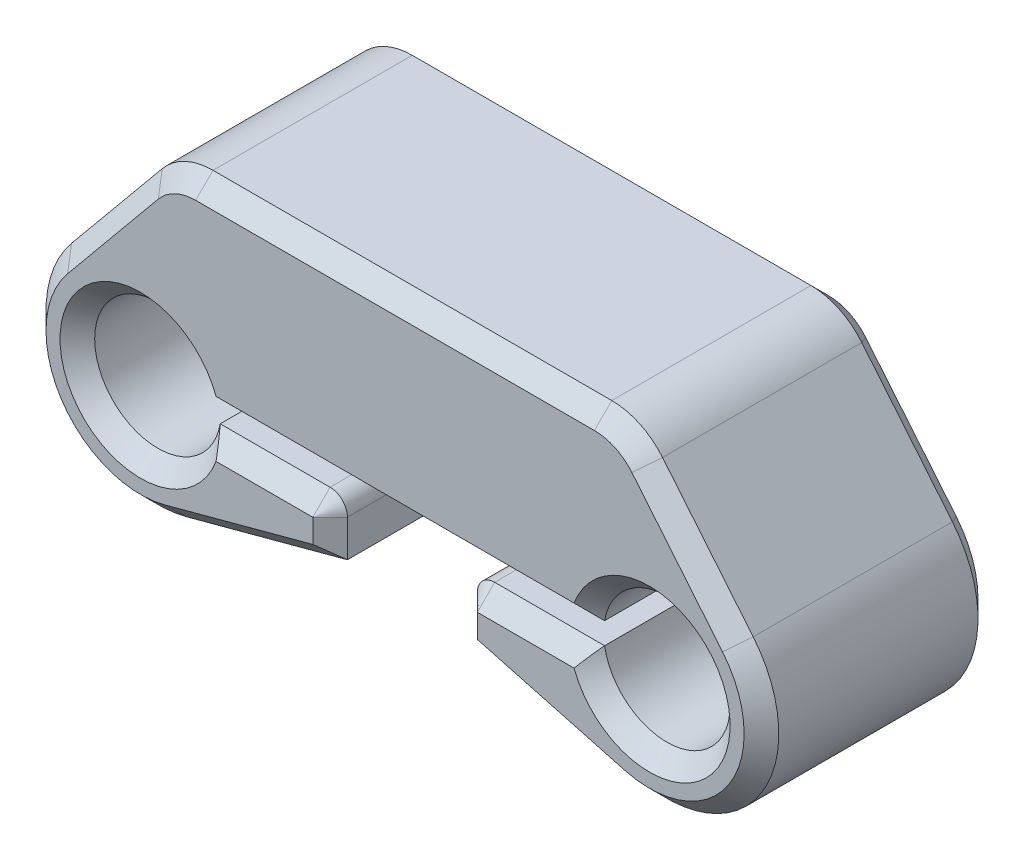
from build123d import *

# Parameters (mm, degrees)
BOSS_EXTRUDE2_DEPTH = 34.29
CHAMFER1_SIZE       = 2.54
CHAMFER2_SIZE       = 2.54


with BuildPart() as part:
    # Sketch2 → Boss-Extrude2 (new body)
    with BuildSketch(Plane.XY):
        with BuildLine():
            Line((-29.230640855, 30.0736), (29.230640855, 30.0736))
            ThreePointArc((29.230640855, 30.0736), (33.347275907, 29.151687047), (36.677508311, 26.562061635))
            Line((36.677508311, 26.562061635), (49.972274675, 10.43878478))
            ThreePointArc((49.972274675, 10.43878478), (51.110407437, -8.880095747), (33.055391111, -15.846506335))
            Line((33.055391111, -15.846506335), (9.525, -9.525))
            Line((9.525, -9.525), (9.525, -4.1275))
            ThreePointArc((9.525, -4.1275), (10.268948776, -2.331448776), (12.065, -1.5875))
            Line((12.065, -1.5875), (28.178527264, -1.5875))
            ThreePointArc((28.178527264, -1.5875), (46.5836, 0), (28.178527264, 1.5875))
            Line((28.178527264, 1.5875), (-28.178527264, 1.5875))
            ThreePointArc((-28.178527264, 1.5875), (-46.5836, 0), (-28.178527264, -1.5875))
            Line((-28.178527264, -1.5875), (-12.065, -1.5875))
            ThreePointArc((-12.065, -1.5875), (-10.268948776, -2.331448776), (-9.525, -4.1275))
            Line((-9.525, -4.1275), (-9.525, -9.525))
            Line((-9.525, -9.525), (-33.055391111, -15.846506335))
            ThreePointArc((-33.055391111, -15.846506335), (-51.110407437, -8.880095747), (-49.972274675, 10.43878478))
            Line((-49.972274675, 10.43878478), (-36.677508311, 26.562061635))
            ThreePointArc((-36.677508311, 26.562061635), (-33.347275907, 29.151687047), (-29.230640855, 30.0736))
        make_face()
    extrude(amount=BOSS_EXTRUDE2_DEPTH)

    # Chamfer1
    chamfer1_edges = [part.edges().sort_by_distance(p)[0] for p in [
        (33.347275907, 29.151687047, 34.29),
        (0, 30.0736, 34.29),
        (-33.347275907, 29.151687047, 34.29),
        (-43.324891493, 18.500423208, 34.29),
        (-51.110407437, -8.880095747, 34.29),
        (-21.290195556, -12.685753168, 34.29),
        (-9.525, -6.82625, 34.29),
        (-10.268948776, -2.331448776, 34.29),
        (-20.121763632, -1.5875, 34.29),
        (-46.5836, 0, 34.29),
        (51.110407437, -8.880095747, 34.29),
        (0, 1.5875, 34.29),
        (46.5836, 0, 34.29),
        (20.121763632, -1.5875, 34.29),
        (10.268948776, -2.331448776, 34.29),
        (9.525, -6.82625, 34.29),
        (21.290195556, -12.685753168, 34.29),
        (43.324891493, 18.500423208, 34.29),
    ]]
    chamfer(chamfer1_edges, length=CHAMFER1_SIZE)

    # Chamfer2
    chamfer2_edges = [part.edges().sort_by_distance(p)[0] for p in [
        (21.290195556, -12.685753168, 0),
        (-21.290195556, -12.685753168, 0),
        (-51.110407437, -8.880095747, 0),
        (-43.324891493, 18.500423208, 0),
        (-33.347275907, 29.151687047, 0),
        (0, 30.0736, 0),
        (33.347275907, 29.151687047, 0),
        (43.324891493, 18.500423208, 0),
        (51.110407437, -8.880095747, 0),
    ]]
    chamfer(chamfer2_edges, length=CHAMFER2_SIZE)


solid = part.part
